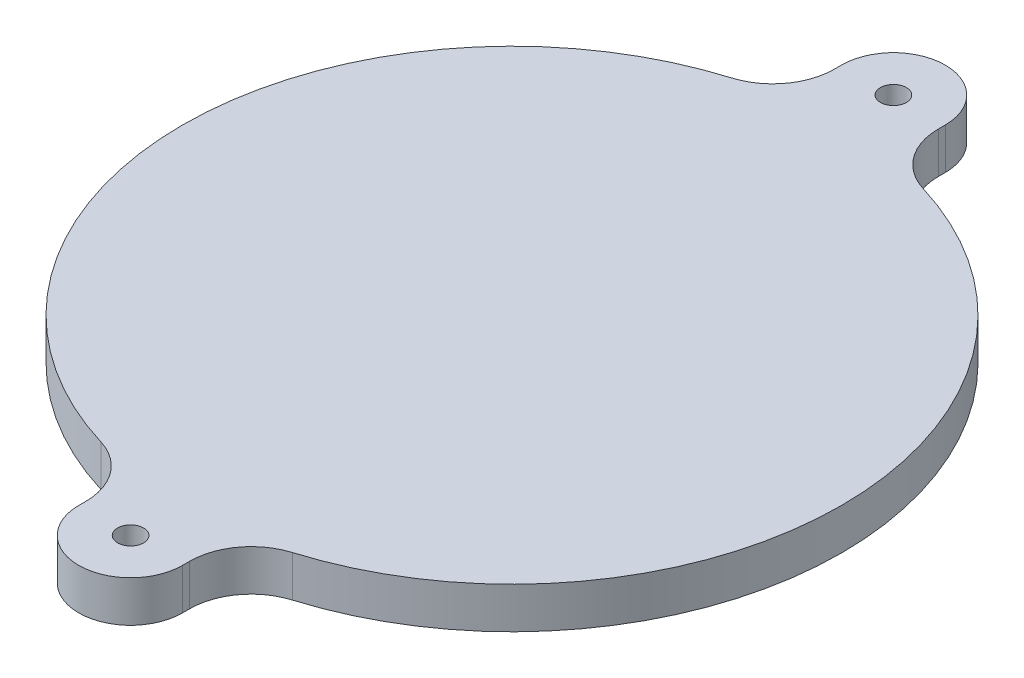
from build123d import *

# Parameters (mm, degrees)
BOSS_EXTRUDE1_START = 1
SKETCH1_R           = 25.4
SKETCH1_R_2         = 1
BOSS_EXTRUDE1_DEPTH = 3.175
FILLET1_R           = 4.7625


with BuildPart() as part:
    # Sketch1 → Boss-Extrude1 (new body)
    with BuildSketch(Plane.XZ.offset(0.396875).offset(BOSS_EXTRUDE1_START)):
        Circle(SKETCH1_R)
        with BuildLine():
            Line((4, 29.4), (4, -29.4))
            ThreePointArc((4, -29.4), (0, -33.4), (-4, -29.4))
            Line((-4, -29.4), (-4, 29.4))
            ThreePointArc((-4, 29.4), (0, 33.4), (4, 29.4))
        make_face()
        with Locations((0, 29.4)):
            Circle(SKETCH1_R_2, mode=Mode.SUBTRACT)
        with Locations((0, -29.4)):
            Circle(SKETCH1_R_2, mode=Mode.SUBTRACT)
    extrude(amount=BOSS_EXTRUDE1_DEPTH)

    # Fillet1
    fillet1_edges = [part.edges().sort_by_distance(p)[0] for p in [
        (-4, -2.984375, -25.083062014),
        (-4, -2.984375, 25.083062014),
        (4, -2.984375, 25.083062014),
        (4, -2.984375, -25.083062014),
    ]]
    fillet(fillet1_edges, radius=FILLET1_R)


solid = part.part
